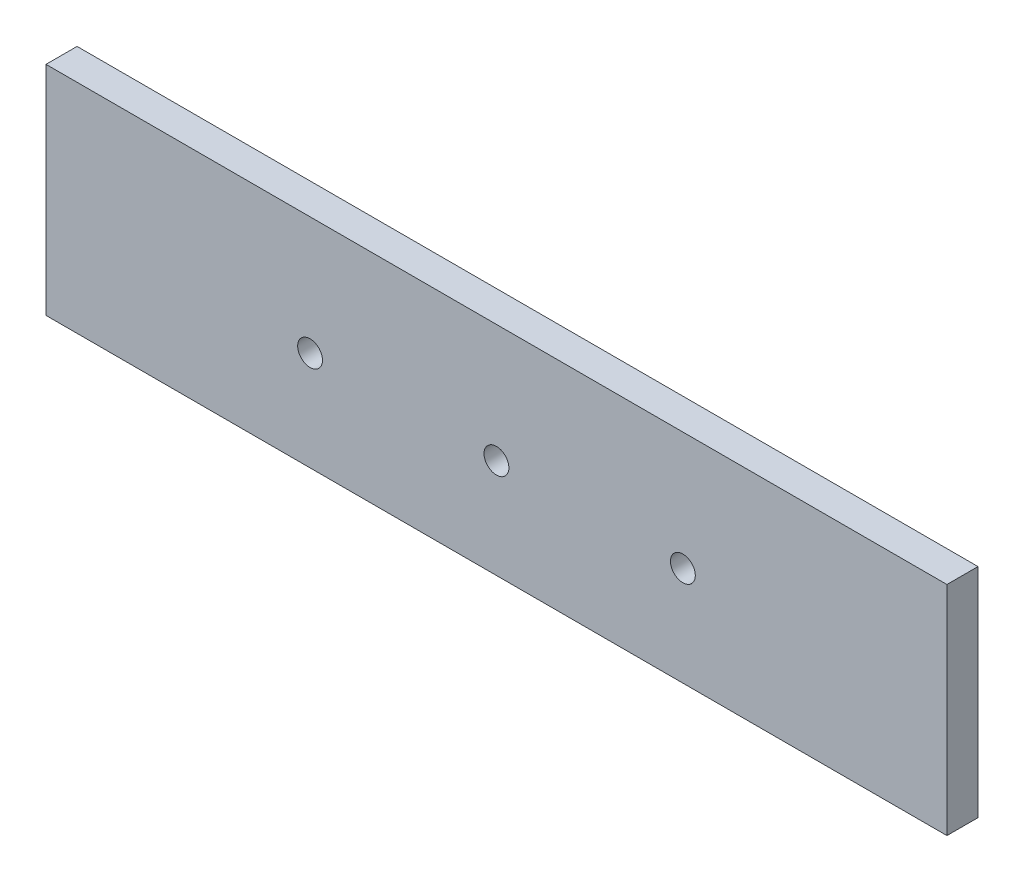
from build123d import *

# Parameters (mm, degrees)
SKETCH1_W           = 184.15
SKETCH1_H           = 44.45
BOSS_EXTRUDE1_DEPTH = 6.35
SKETCH2_R           = 2.54
CUT_EXTRUDE1_DEPTH  = 7.35


with BuildPart() as part:
    # Sketch1 → Boss-Extrude1 (new body)
    with BuildSketch(Plane.XY):
        Rectangle(SKETCH1_W, SKETCH1_H)
    extrude(amount=BOSS_EXTRUDE1_DEPTH)

    # Sketch2 → Cut-Extrude1 (cut, through all)
    with BuildSketch(Plane.XY.offset(6.35)):
        with Locations((-38.1, -1.905)):
            Circle(SKETCH2_R)
        with Locations((0, -1.905)):
            Circle(SKETCH2_R)
        with Locations((38.1, -1.905)):
            Circle(SKETCH2_R)
    extrude(amount=-CUT_EXTRUDE1_DEPTH, mode=Mode.SUBTRACT)


solid = part.part
